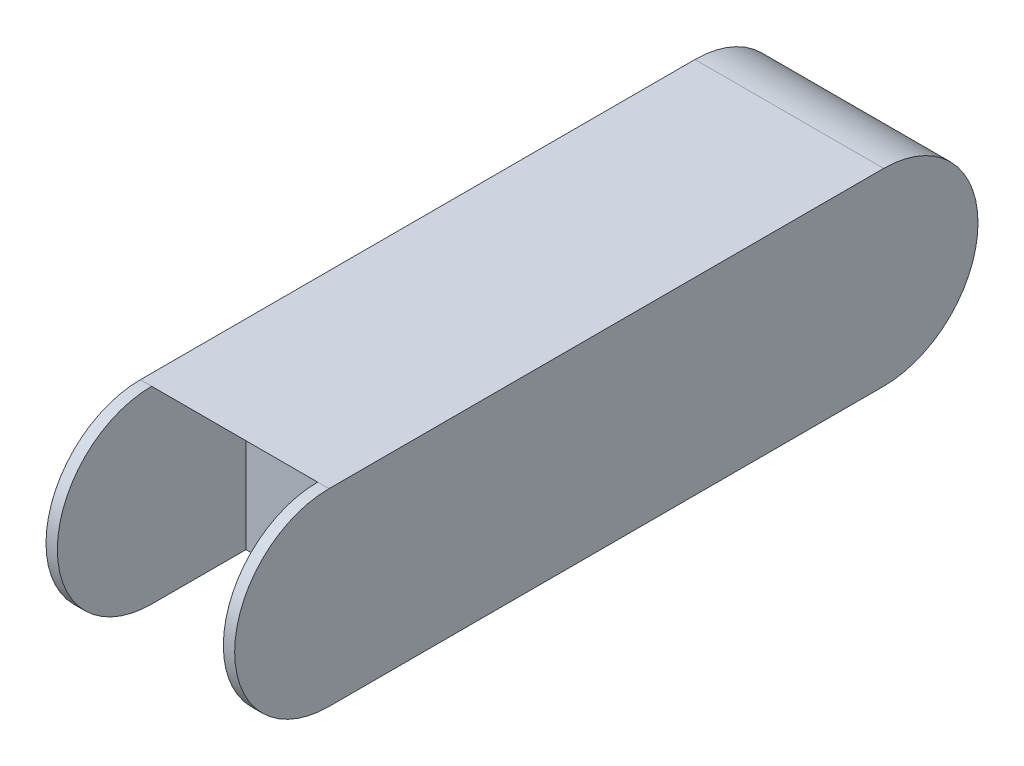
from build123d import *

# Parameters (mm, degrees)
BOSS_EXTRUDE1_DEPTH = 0.05
SKETCH2_W           = 0.025
SKETCH2_H           = 0.025
CUT_EXTRUDE1_DEPTH  = 0.05
SKETCH4_R           = 0.025
BOSS_EXTRUDE2_DEPTH = 0.003
SKETCH5_R           = 0.025
BOSS_EXTRUDE3_DEPTH = 0.003
SKETCH6_W           = 0.025
SKETCH6_H           = 0.025
BOSS_EXTRUDE4_DEPTH = 0.003
SKETCH7_W           = 0.025
SKETCH7_H           = 0.025
BOSS_EXTRUDE5_DEPTH = 0.003


with BuildPart() as part:
    # Sketch1 → Boss-Extrude1 (new body)
    with BuildSketch(Plane(origin=(0, 0, 0), x_dir=(0, 0, -1), z_dir=(1, 0, 0))):
        with BuildLine():
            Line((0, 0), (0.147, 0))
            ThreePointArc((0.147, 0), (0.172, 0.025), (0.147, 0.05))
            Line((0.147, 0.05), (0, 0.05))
            ThreePointArc((0, 0.05), (0.025, 0.025), (0, 0))
        make_face()
    extrude(amount=BOSS_EXTRUDE1_DEPTH)

    # Sketch2 → Cut-Extrude1 (cut)
    with BuildSketch(Plane(origin=(0.05, 0, 0), x_dir=(0, 0, -1), z_dir=(1, 0, 0))):
        with Locations((0.0125, 0.0125)):
            Rectangle(SKETCH2_W, SKETCH2_H)
    extrude(amount=-CUT_EXTRUDE1_DEPTH, mode=Mode.SUBTRACT)

    # Sketch4 → Boss-Extrude2 (add)
    with BuildSketch(Plane(origin=(0.05, 0, 0), x_dir=(0, 0, -1), z_dir=(1, 0, 0))):
        with Locations((0, 0.025)):
            Circle(SKETCH4_R)
    extrude(amount=-BOSS_EXTRUDE2_DEPTH)

    # Sketch5 → Boss-Extrude3 (add)
    with BuildSketch(Plane.ZY):
        with Locations((0, 0.025)):
            Circle(SKETCH5_R)
    extrude(amount=-BOSS_EXTRUDE3_DEPTH)

    # Sketch6 → Boss-Extrude4 (add)
    with BuildSketch(Plane.ZY):
        with Locations((-0.0125, 0.0125)):
            Rectangle(SKETCH6_W, SKETCH6_H)
    extrude(amount=-BOSS_EXTRUDE4_DEPTH)

    # Sketch7 → Boss-Extrude5 (add)
    with BuildSketch(Plane(origin=(0.05, 0, 0), x_dir=(0, 0, -1), z_dir=(1, 0, 0))):
        with Locations((0.0125, 0.0125)):
            Rectangle(SKETCH7_W, SKETCH7_H)
    extrude(amount=-BOSS_EXTRUDE5_DEPTH)


solid = part.part
